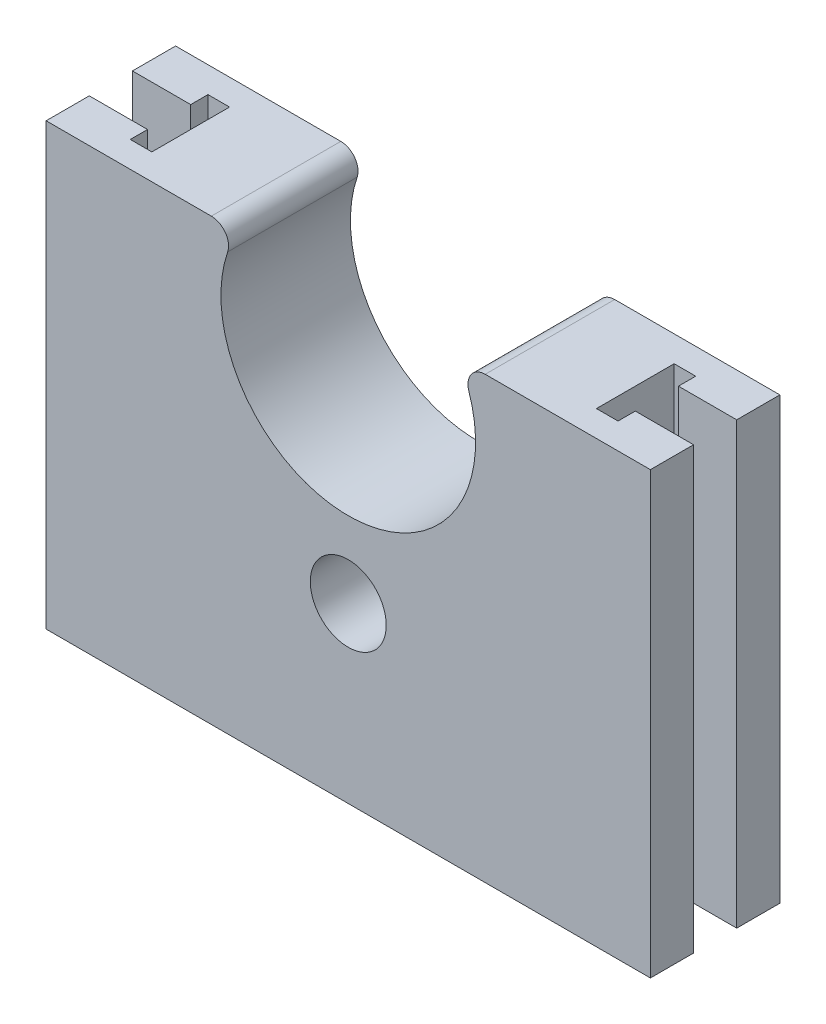
from build123d import *

# Parameters (mm, degrees)
BOSS_EXTRUDE1_DEPTH = 15
SKETCH5_R           = 4.4
CUT_EXTRUDE3_DEPTH  = 16
SKETCH3_W           = 16
SKETCH3_H           = 5
SKETCH3_W_2         = 2.5
SKETCH3_H_2         = 9
CUT_EXTRUDE4_DEPTH  = 52


with BuildPart() as part:
    # Sketch2 → Boss-Extrude1 (new body)
    with BuildSketch(Plane.XY):
        with BuildLine():
            Line((42.400497512, 28.014925373), (23.264667046, 28.014925373))
            ThreePointArc((23.264667046, 28.014925373), (21.639308303, 27.180347595), (21.370437848, 25.373134328))
            ThreePointArc((21.370437848, 25.373134328), (7.400497512, 5.889925373), (-6.569442823, 25.373134328))
            ThreePointArc((-6.569442823, 25.373134328), (-6.838313278, 27.180347595), (-8.463672021, 28.014925373))
            Line((-8.463672021, 28.014925373), (-27.599502488, 28.014925373))
            Line((-27.599502488, 28.014925373), (-27.599502488, -22.985074627))
            Line((-27.599502488, -22.985074627), (42.400497512, -22.985074627))
            Line((42.400497512, -22.985074627), (42.400497512, 28.014925373))
        make_face()
    extrude(amount=BOSS_EXTRUDE1_DEPTH)

    # Sketch5 → Cut-Extrude3 (cut, through all)
    with BuildSketch(Plane.XY.offset(15)):
        with Locations((7.400497512, -2.910074627)):
            Circle(SKETCH5_R)
    extrude(amount=-CUT_EXTRUDE3_DEPTH, mode=Mode.SUBTRACT)

    # Sketch3 → Cut-Extrude4 (cut, through all)
    with BuildSketch(Plane(origin=(0, 28.014925373, 0), x_dir=(1, 0, 0), z_dir=(0, 1, 0))):
        with Locations((-27.599502488, -7.5)):
            Rectangle(SKETCH3_W, SKETCH3_H)
        with Locations((42.400497512, -7.5)):
            Rectangle(SKETCH3_W, SKETCH3_H)
        with Locations((-19.599502488, -7.49995864)):
            Rectangle(SKETCH3_W_2, SKETCH3_H_2)
        with Locations((34.400497512, -7.5)):
            Rectangle(SKETCH3_W_2, SKETCH3_H_2)
    extrude(amount=-CUT_EXTRUDE4_DEPTH, mode=Mode.SUBTRACT)


solid = part.part
